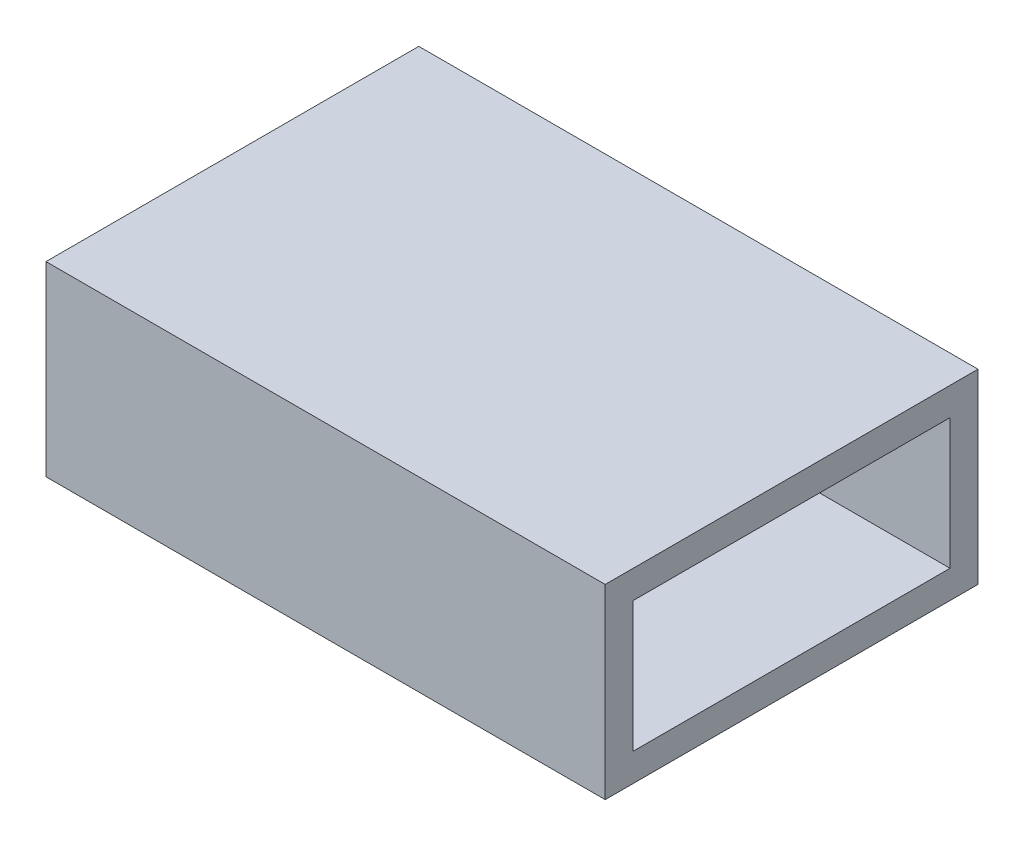
from build123d import *

# Parameters (mm, degrees)
SKETCH1_W           = 20
SKETCH1_H           = 10
SKETCH1_W_2         = 17
SKETCH1_H_2         = 7
BOSS_EXTRUDE1_DEPTH = 30


with BuildPart() as part:
    # Sketch1 → Boss-Extrude1 (new body)
    with BuildSketch(Plane(origin=(0, 0, 0), x_dir=(0, 0, -1), z_dir=(1, 0, 0))):
        Rectangle(SKETCH1_W, SKETCH1_H)
        Rectangle(SKETCH1_W_2, SKETCH1_H_2, mode=Mode.SUBTRACT)
    extrude(amount=BOSS_EXTRUDE1_DEPTH)


solid = part.part
